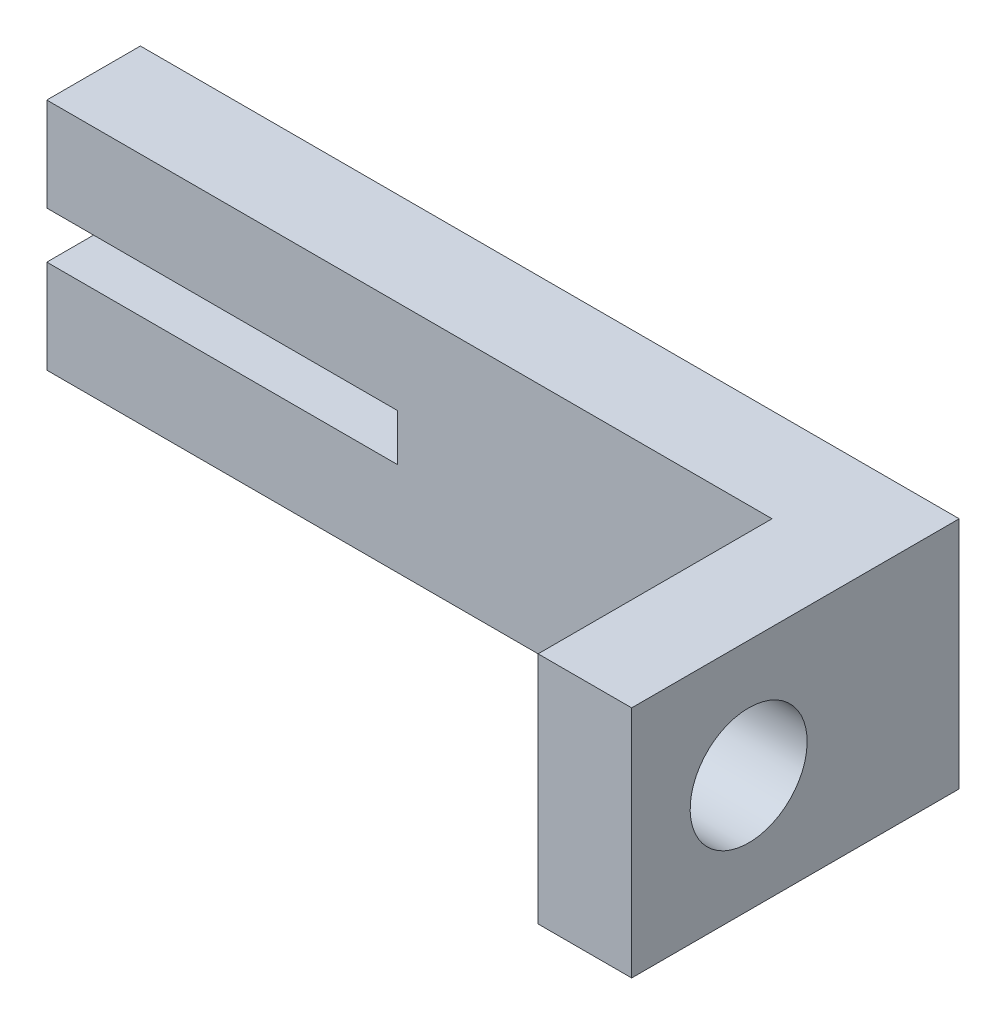
from build123d import *

# Parameters (mm, degrees)
SKETCH1_W           = 15
SKETCH1_H           = 4
BOSS_EXTRUDE1_DEPTH = 4
SKETCH2_W           = 4
SKETCH2_H           = 10
BOSS_EXTRUDE2_DEPTH = 10
SKETCH3_R           = 2.5
CUT_EXTRUDE1_DEPTH  = 10


with BuildPart() as part:
    # Sketch1 → Boss-Extrude1 (new body)
    with BuildSketch(Plane.XY):
        with Locations((7.5, 8)):
            Rectangle(SKETCH1_W, SKETCH1_H)
        Polygon((35, 10), (15, 10), (15, 6), (15, 4), (15, 0), (35, 0), align=None)
        with Locations((7.5, 2)):
            Rectangle(SKETCH1_W, SKETCH1_H)
    extrude(amount=BOSS_EXTRUDE1_DEPTH)

    # Sketch2 → Boss-Extrude2 (add)
    with BuildSketch(Plane.XY.offset(4)):
        with Locations((33, 5)):
            Rectangle(SKETCH2_W, SKETCH2_H)
    extrude(amount=BOSS_EXTRUDE2_DEPTH)

    # Sketch3 → Cut-Extrude1 (cut)
    with BuildSketch(Plane(origin=(35, 0, 0), x_dir=(0, 0, -1), z_dir=(1, 0, 0))):
        with Locations((-9, 5)):
            Circle(SKETCH3_R)
    extrude(amount=-CUT_EXTRUDE1_DEPTH, mode=Mode.SUBTRACT)


solid = part.part
